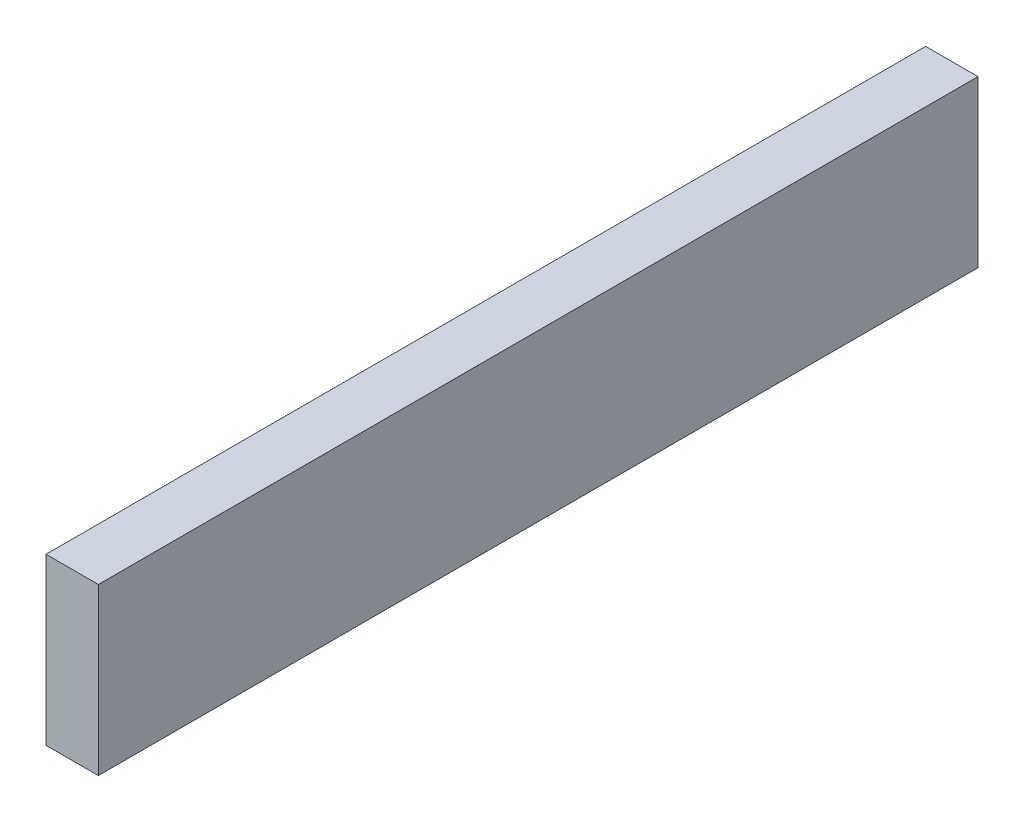
from build123d import *

# Parameters (mm, degrees)
SKETCH1_W           = 50.405822176
SKETCH1_H           = 9.484494468
BOSS_EXTRUDE1_DEPTH = 3


with BuildPart() as part:
    # Sketch1 → Boss-Extrude1 (new body)
    with BuildSketch(Plane(origin=(0, 0, 0), x_dir=(0, 0, -1), z_dir=(1, 0, 0))):
        with Locations((-15.345228226, 0)):
            Rectangle(SKETCH1_W, SKETCH1_H)
    extrude(amount=BOSS_EXTRUDE1_DEPTH)


solid = part.part
